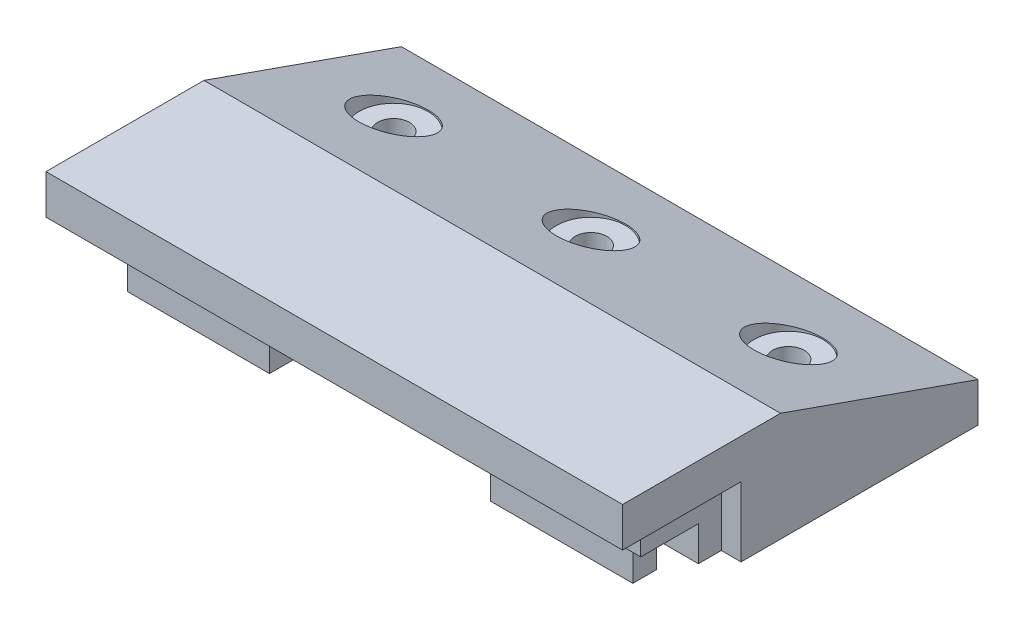
from build123d import *

# Parameters (mm, degrees)
BOSS_EXTRUDE1_DEPTH                                 = 46.355
SKETCH3_W                                           = 86.36
SKETCH3_H                                           = 3.683
BOSS_EXTRUDE2_DEPTH                                 = 11.176
SKETCH3_3_W                                         = 86.36
SKETCH3_3_H                                         = 9.271
BOSS_EXTRUDE3_DEPTH                                 = 5.588
SKETCH4_W                                           = 22.86
SKETCH4_H                                           = 3.81
BOSS_EXTRUDE4_DEPTH                                 = 5.588
CBORE_FOR_10_BINDING_HEAD_MACHINE_SCREW_D           = 5.1054
CBORE_FOR_10_BINDING_HEAD_MACHINE_SCREW_CBORE_D     = 11.1125
CBORE_FOR_10_BINDING_HEAD_MACHINE_SCREW_CBORE_DEPTH = 7.747


with BuildPart() as part:
    # Sketch2 → Boss-Extrude1 (new body, symmetric)
    with BuildSketch(Plane(origin=(0, 0, 0), x_dir=(0, 0, -1), z_dir=(1, 0, 0))):
        Polygon((19.05, 0), (19.05, -11.176), (57.15, -11.176), (57.15, -4.826), (25.4, 6.35), (0, 6.35), (0, 0), align=None)
    extrude(amount=BOSS_EXTRUDE1_DEPTH, both=True)

    # Sketch3 → Boss-Extrude2 (add)
    with BuildSketch(Plane.XZ):
        with Locations((0, -17.2085)):
            Rectangle(SKETCH3_W, SKETCH3_H)
    extrude(amount=BOSS_EXTRUDE2_DEPTH)

    # Sketch3_3 → Boss-Extrude3 (add)
    with BuildSketch(Plane.XZ):
        with Locations((0, -10.7315)):
            Rectangle(SKETCH3_3_W, SKETCH3_3_H)
    extrude(amount=BOSS_EXTRUDE3_DEPTH)

    # Sketch4 → Boss-Extrude4 (add)
    with BuildSketch(Plane.XZ.offset(5.588)):
        with Locations((-29.21, -9.271)):
            Rectangle(SKETCH4_W, SKETCH4_H)
        with Locations((29.21, -9.271)):
            Rectangle(SKETCH4_W, SKETCH4_H)
    extrude(amount=BOSS_EXTRUDE4_DEPTH)

    # CBORE for _10 Binding Head Machine Screw (through all)
    with Locations(Plane(origin=(0, 6.35, 0), x_dir=(-1, 0, 0), z_dir=(0, 1, 0))):
        with Locations((-31.75, -41.275), (0, -41.275), (31.75, -41.275)):
            CounterBoreHole(CBORE_FOR_10_BINDING_HEAD_MACHINE_SCREW_D / 2, CBORE_FOR_10_BINDING_HEAD_MACHINE_SCREW_CBORE_D / 2, CBORE_FOR_10_BINDING_HEAD_MACHINE_SCREW_CBORE_DEPTH)


solid = part.part
